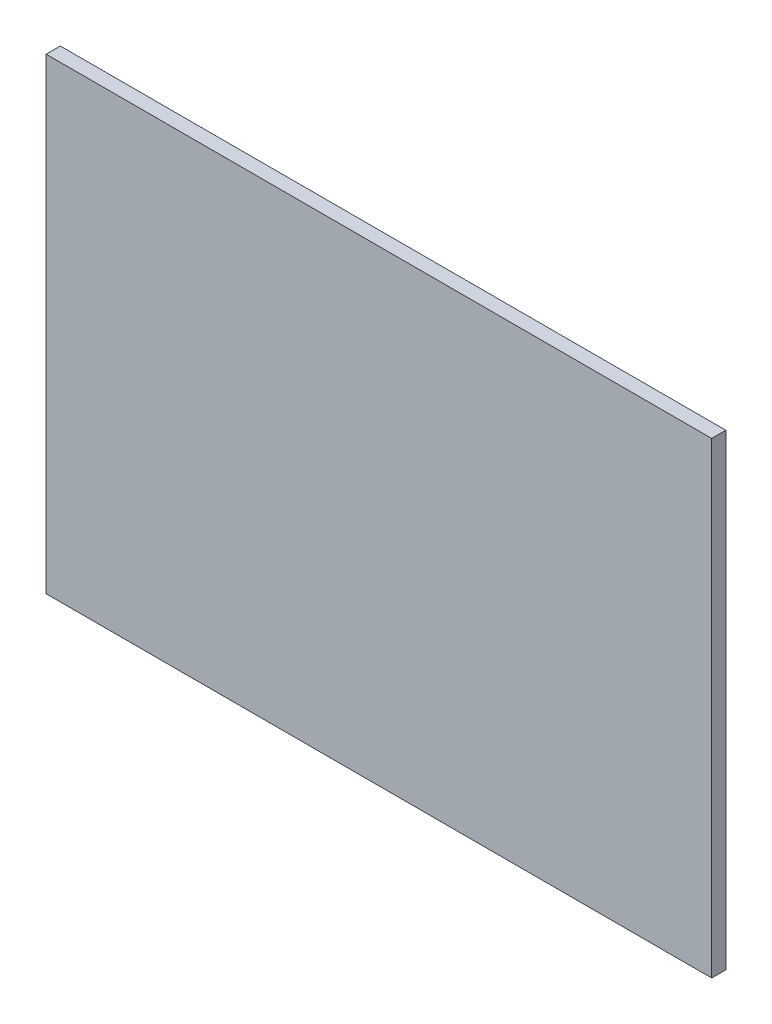
from build123d import *

# Parameters (mm, degrees)
SKETCH_1_W      = 470
SKETCH_1_H      = 330
EXTRUDE_1_DEPTH = 10


with BuildPart() as part:
    # Эскиз1 → Бобышка-Вытянуть1 (new body)
    with BuildSketch(Plane.XY):
        with Locations((235, 165)):
            Rectangle(SKETCH_1_W, SKETCH_1_H)
    extrude(amount=EXTRUDE_1_DEPTH)


solid = part.part
